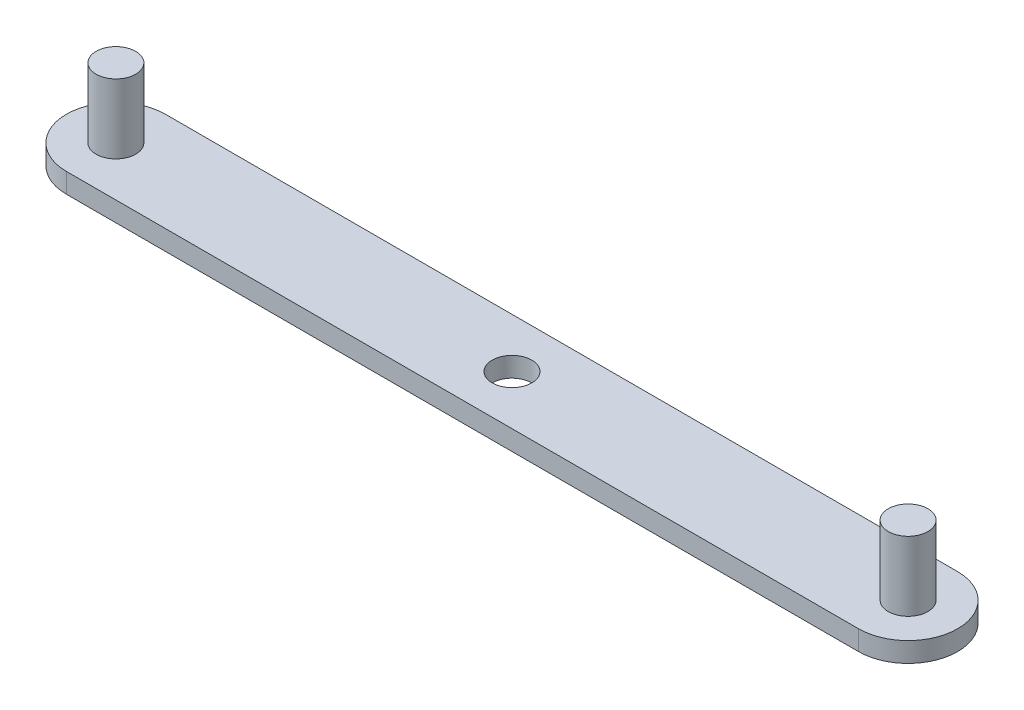
from build123d import *

# Parameters (mm, degrees)
EXTRUDE_1_DEPTH     = 2
SKETCH_2_R          = 2
EXTRUDE_2_DEPTH     = 7
CUT_EXTRUDE_2_DEPTH = 10


with BuildPart() as part:
    # 草图1 → 凸台-拉伸1 (new body)
    with BuildSketch(Plane(origin=(0, 0, 0), x_dir=(1, 0, 0), z_dir=(0, 1, 0))):
        with BuildLine():
            Line((-65, 5), (15, 5))
            ThreePointArc((15, 5), (20, 0), (15, -5))
            Line((15, -5), (-65, -5))
            ThreePointArc((-65, -5), (-70, 0), (-65, 5))
        make_face()
    extrude(amount=EXTRUDE_1_DEPTH)

    # 草图2 → 凸台-拉伸2 (add)
    with BuildSketch(Plane(origin=(0, 2, 0), x_dir=(1, 0, 0), z_dir=(0, 1, 0))):
        with Locations((15, 0)):
            Circle(SKETCH_2_R)
        with BuildLine():
            ThreePointArc((-63, 0), (-63.585786438, 1.414213562), (-65, 2))
            Line((-65, 2), (-65, -2))
            ThreePointArc((-65, -2), (-63.585786438, -1.414213562), (-63, 0))
        make_face()
        with BuildLine():
            Line((-65, -2), (-65, 2))
            ThreePointArc((-65, 2), (-67, 0), (-65, -2))
        make_face()
    extrude(amount=EXTRUDE_2_DEPTH)

    # 草图4 → 切除-拉伸2 (cut)
    with BuildSketch(Plane.XZ):
        with BuildLine():
            ThreePointArc((-23.015444247, 0.248069469), (-25.248069469, 1.984555753), (-26.984555753, -0.248069469))
            Line((-26.984555753, -0.248069469), (-23.015444247, 0.248069469))
        make_face()
        with BuildLine():
            Line((-23.015444247, 0.248069469), (-26.984555753, -0.248069469))
            ThreePointArc((-26.984555753, -0.248069469), (-24.875725117, -1.996135204), (-23, 0))
            ThreePointArc((-23, 0), (-23.003864796, 0.124274883), (-23.015444247, 0.248069469))
        make_face()
    extrude(amount=-CUT_EXTRUDE_2_DEPTH, mode=Mode.SUBTRACT)


solid = part.part
